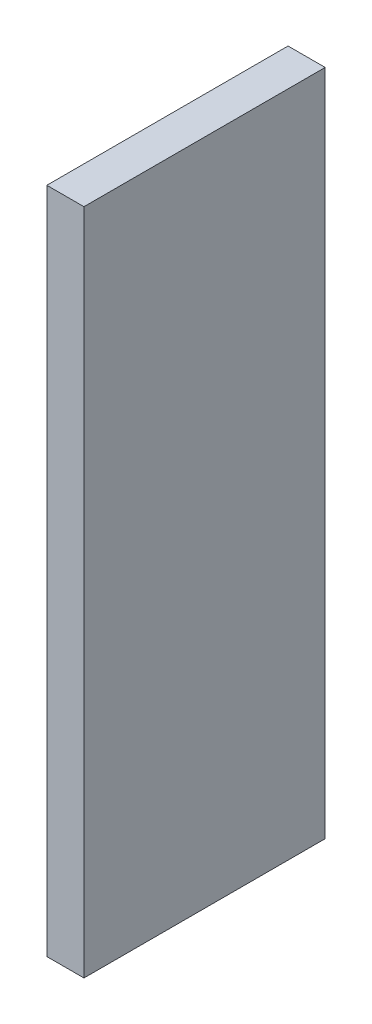
from build123d import *

# Parameters (mm, degrees)
BOSS_EXTRUDE1_DEPTH = 13


with BuildPart() as part:
    # Sketch1 → Boss-Extrude1 (new body)
    with BuildSketch(Plane(origin=(0, 0, 0), x_dir=(1, 0, 0), z_dir=(0, 0, -1))):
        Polygon((0, -18), (2, -18), (2, 0), (2, 18), (0, 18), (0, 0), align=None)
    extrude(amount=BOSS_EXTRUDE1_DEPTH)


solid = part.part
